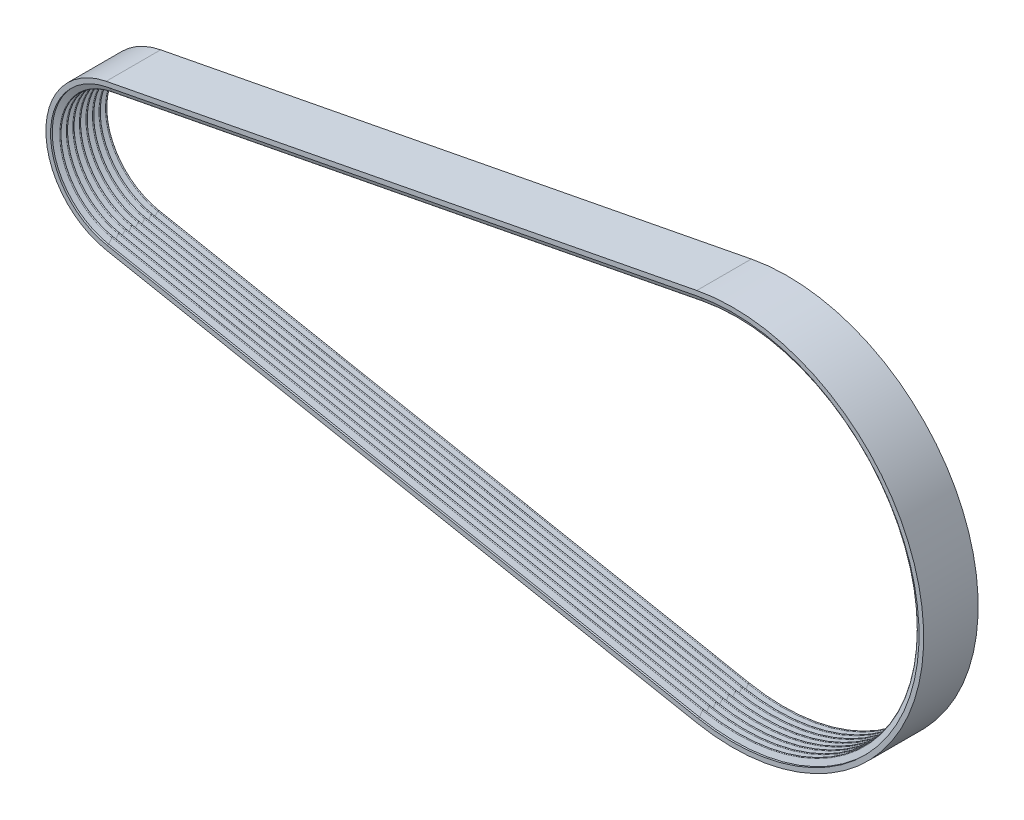
from build123d import *


with BuildPart() as part:
    # Sweep1: sweep along a path in Sketch1
    with BuildLine(Plane.XY) as sweep1_path:
        Line((-7.230150296, 37.407685396), (315.339199211, 99.753827723))
        ThreePointArc((315.339199211, 99.753827723), (436.2196, 0), (315.339199211, -99.753827723))
        Line((315.339199211, -99.753827723), (-7.230150296, -37.407685396))
        ThreePointArc((-7.230150296, -37.407685396), (-38.1, 0), (-7.230150296, 37.407685396))
    # Sketch2 → Sweep1 (sweep)
    with BuildSketch(Plane(origin=(-7.230150296, 37.407685396, 0), x_dir=(0, 0, -1), z_dir=(0.9818290130220897, 0.18976772430545014, 0))):
        with BuildLine():
            Line((0, 2.54), (14.879437111, 2.54))
            Line((14.879437111, 2.54), (14.879437111, 0))
            Line((14.879437111, 0), (13.926937111, 0))
            Line((13.926937111, 0), (12.857362889, -2.938631026))
            ThreePointArc((12.857362889, -2.938631026), (12.49934, -3.189321351), (12.141317111, -2.938631026))
            Line((12.141317111, -2.938631026), (11.071742889, 0))
            ThreePointArc((11.071742889, 0), (10.71372, 0.250690325), (10.355697111, 0))
            Line((10.355697111, 0), (9.286122889, -2.938631026))
            ThreePointArc((9.286122889, -2.938631026), (8.9281, -3.189321351), (8.570077111, -2.938631026))
            Line((8.570077111, -2.938631026), (7.500502889, 0))
            ThreePointArc((7.500502889, 0), (7.14248, 0.250690325), (6.784457111, 0))
            Line((6.784457111, 0), (5.714882889, -2.938631026))
            ThreePointArc((5.714882889, -2.938631026), (5.35686, -3.189321351), (4.998837111, -2.938631026))
            Line((4.998837111, -2.938631026), (3.929262889, 0))
            ThreePointArc((3.929262889, 0), (3.57124, 0.250690325), (3.213217111, 0))
            Line((3.213217111, 0), (2.143642889, -2.938631026))
            ThreePointArc((2.143642889, -2.938631026), (1.78562, -3.189321351), (1.427597111, -2.938631026))
            Line((1.427597111, -2.938631026), (0.358022889, 0))
            ThreePointArc((0.358022889, 0), (0.218532622, 0.181787254), (0, 0.250690325))
            Line((0, 0.250690325), (0, 2.54))
        make_face()
    sweep1 = sweep(path=sweep1_path.line)

    # Mirror1: Sweep1 across Front Plane
    add(sweep1.mirror(Plane.XY))


solid = part.part
